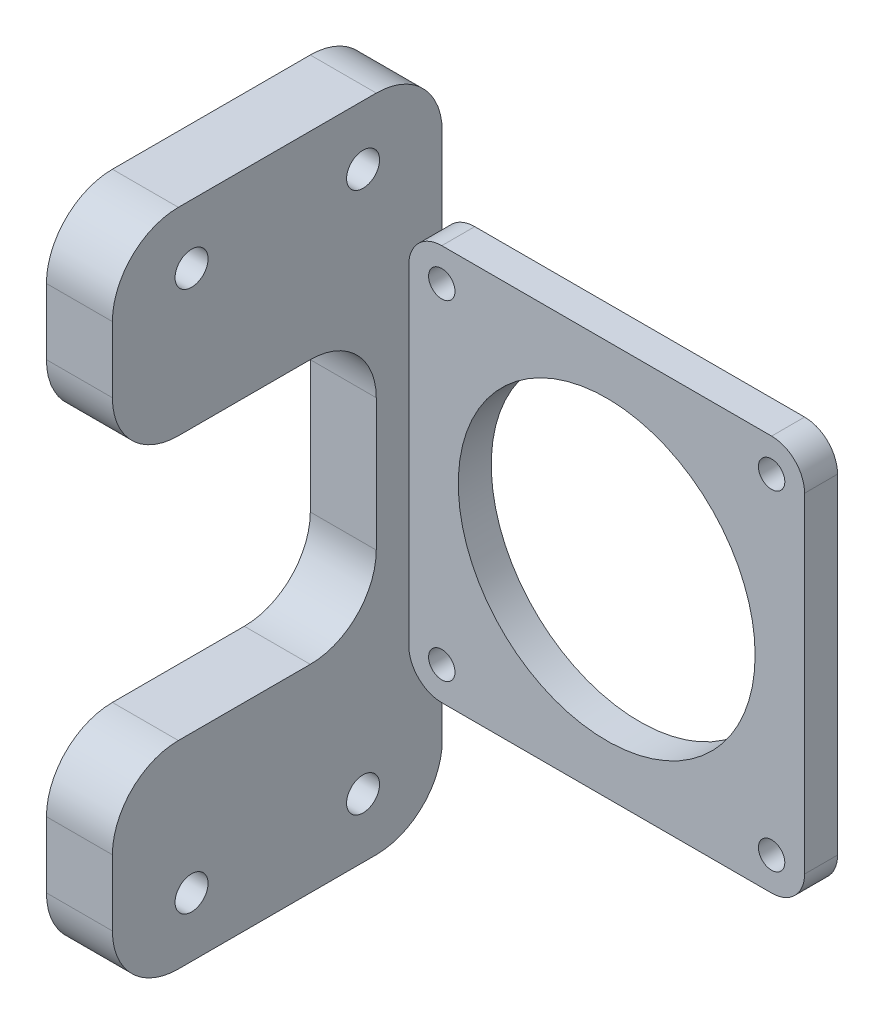
from build123d import *

# Parameters (mm, degrees)
SKETCH2_R           = 2
SKETCH2_R_2         = 22.5
BOSS_EXTRUDE2_DEPTH = 5
SKETCH3_R           = 2.5
BOSS_EXTRUDE3_DEPTH = 10


with BuildPart() as part:
    # Sketch2 → Boss-Extrude2 (new body)
    with BuildSketch(Plane.XY):
        with BuildLine():
            Line((25, 30), (-25, 30))
            ThreePointArc((-25, 30), (-28.535533906, 28.535533906), (-30, 25))
            Line((-30, 25), (-30, -25))
            ThreePointArc((-30, -25), (-28.535533906, -28.535533906), (-25, -30))
            Line((-25, -30), (25, -30))
            ThreePointArc((25, -30), (28.535533906, -28.535533906), (30, -25))
            Line((30, -25), (30, 25))
            ThreePointArc((30, 25), (28.535533906, 28.535533906), (25, 30))
        make_face()
        with Locations((-25, 25)):
            Circle(SKETCH2_R, mode=Mode.SUBTRACT)
        with Locations((25, 25)):
            Circle(SKETCH2_R, mode=Mode.SUBTRACT)
        with Locations((25, -25)):
            Circle(SKETCH2_R, mode=Mode.SUBTRACT)
        with Locations((-25, -25)):
            Circle(SKETCH2_R, mode=Mode.SUBTRACT)
        Circle(SKETCH2_R_2, mode=Mode.SUBTRACT)
    extrude(amount=BOSS_EXTRUDE2_DEPTH)

    # Sketch3 → Boss-Extrude3 (add)
    with BuildSketch(Plane.ZY.offset(30)):
        with BuildLine():
            Line((39.932932244, 50), (9.932932244, 50))
            ThreePointArc((9.932932244, 50), (2.861864432, 47.071067812), (-0.067067756, 40))
            Line((-0.067067756, 40), (-0.067067756, -40))
            ThreePointArc((-0.067067756, -40), (2.861864432, -47.071067812), (9.932932244, -50))
            Line((9.932932244, -50), (39.932932244, -50))
            ThreePointArc((39.932932244, -50), (47.004000055, -47.071067812), (49.932932244, -40))
            Line((49.932932244, -40), (49.932932244, -30))
            ThreePointArc((49.932932244, -30), (47.004000055, -22.928932188), (39.932932244, -20))
            Line((39.932932244, -20), (19.932932244, -20))
            ThreePointArc((19.932932244, -20), (12.861864432, -17.071067812), (9.932932244, -10))
            Line((9.932932244, -10), (9.932932244, 10))
            ThreePointArc((9.932932244, 10), (12.861864432, 17.071067812), (19.932932244, 20))
            Line((19.932932244, 20), (39.932932244, 20))
            ThreePointArc((39.932932244, 20), (47.004000055, 22.928932188), (49.932932244, 30))
            Line((49.932932244, 30), (49.932932244, 40))
            ThreePointArc((49.932932244, 40), (47.004000055, 47.071067812), (39.932932244, 50))
        make_face()
        with Locations((11.932932244, -41)):
            Circle(SKETCH3_R, mode=Mode.SUBTRACT)
        with Locations((37.932932244, -41)):
            Circle(SKETCH3_R, mode=Mode.SUBTRACT)
        with Locations((11.932932244, 41)):
            Circle(SKETCH3_R, mode=Mode.SUBTRACT)
        with Locations((37.932932244, 41)):
            Circle(SKETCH3_R, mode=Mode.SUBTRACT)
    extrude(amount=BOSS_EXTRUDE3_DEPTH)


solid = part.part
